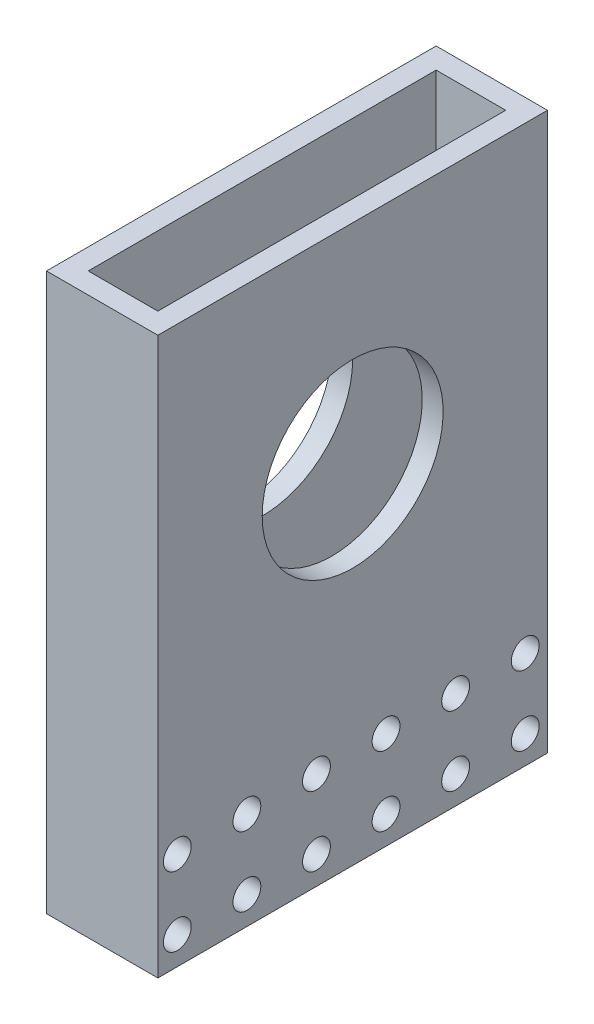
from build123d import *

# Parameters (mm, degrees)
SKETCH1_W           = 16
SKETCH1_H           = 56
SKETCH1_W_2         = 10
SKETCH1_H_2         = 50
EXTRUDE_THIN1_DEPTH = 80
SKETCH2_R           = 13
SKETCH2_R_2         = 2
CUT_EXTRUDE1_DEPTH  = 17


with BuildPart() as part:
    # Sketch1 → Extrude-Thin1 (new body)
    with BuildSketch(Plane(origin=(0, 0, 0), x_dir=(1, 0, 0), z_dir=(0, 1, 0))):
        Rectangle(SKETCH1_W, SKETCH1_H)
        Rectangle(SKETCH1_W_2, SKETCH1_H_2, mode=Mode.SUBTRACT)
    extrude(amount=EXTRUDE_THIN1_DEPTH)

    # Sketch2 → Cut-Extrude1 (cut, through all)
    with BuildSketch(Plane.ZY.offset(8)):
        with Locations((0, 50)):
            Circle(SKETCH2_R)
        with Locations((-24.79735893, 4.015533462)):
            Circle(SKETCH2_R_2)
        with Locations((-14.79735893, 4.015533462)):
            Circle(SKETCH2_R_2)
        with Locations((-4.79735893, 4.015533462)):
            Circle(SKETCH2_R_2)
        with Locations((5.20264107, 4.015533462)):
            Circle(SKETCH2_R_2)
        with Locations((15.20264107, 4.015533462)):
            Circle(SKETCH2_R_2)
        with Locations((25.20264107, 4.015533462)):
            Circle(SKETCH2_R_2)
        with Locations((-14.79735893, 14.015533462)):
            Circle(SKETCH2_R_2)
        with Locations((-4.79735893, 14.015533462)):
            Circle(SKETCH2_R_2)
        with Locations((5.20264107, 14.015533462)):
            Circle(SKETCH2_R_2)
        with Locations((15.20264107, 14.015533462)):
            Circle(SKETCH2_R_2)
        with Locations((25.20264107, 14.015533462)):
            Circle(SKETCH2_R_2)
        with Locations((-24.79735893, 14.015533462)):
            Circle(SKETCH2_R_2)
    extrude(amount=-CUT_EXTRUDE1_DEPTH, mode=Mode.SUBTRACT)


solid = part.part
